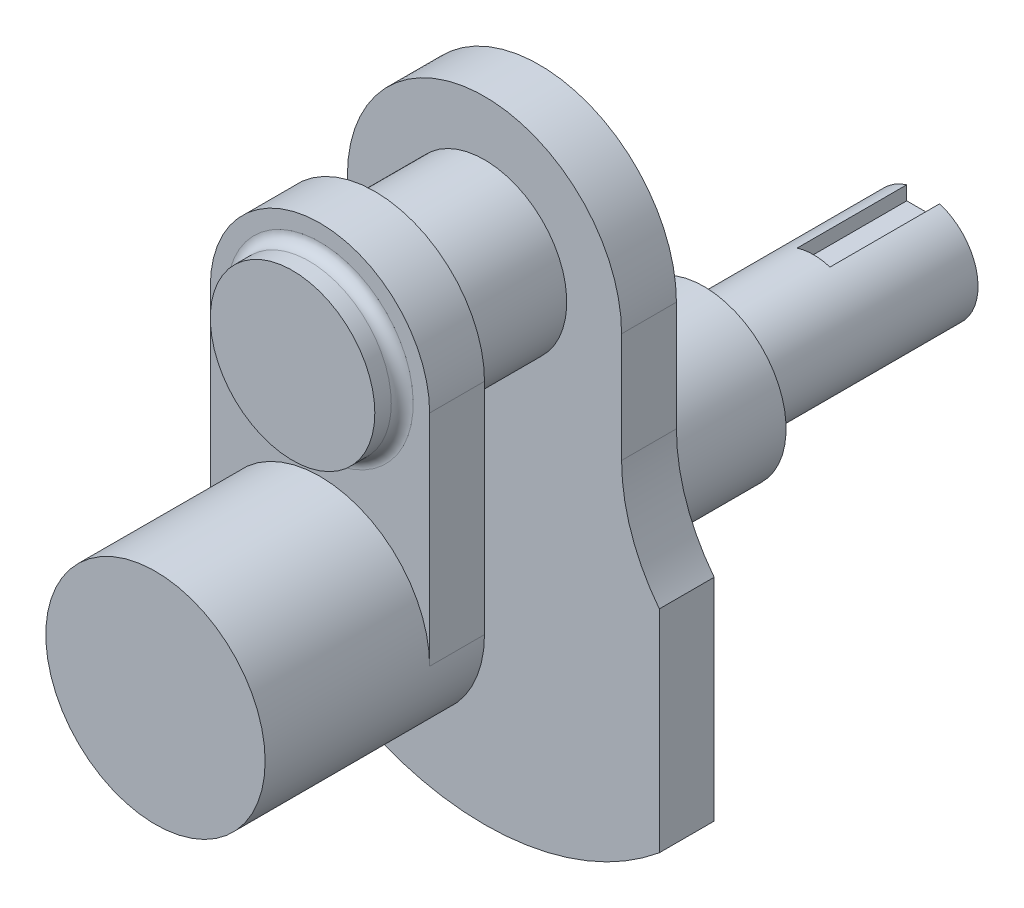
from build123d import *

# Parameters (mm, degrees)
IZIM1_W                          = 40
IZIM1_H                          = 40
Y_KSEKLIK_EKSTR_ZYON1_DEPTH      = 20
KES_EKSTR_ZYON1_DEPTH            = 40
IZIM4_W                          = 10
IZIM4_H                          = 65
Y_KSEKLIK_EKSTR_ZYON2_DEPTH      = 40
KES_EKSTR_ZYON2_DEPTH            = 40
Y_KSEKLIK_EKSTR_ZYON3_DEPTH      = 5
Y_KSEKLIK_EKSTR_ZYON3_DEPTH_BACK = 30
IZIM8_R                          = 15
RADYUS1_R                        = 2
IZIM10_R                         = 15
Y_KSEKLIK_EKSTR_ZYON4_DEPTH      = 10
IZIM10_3_R                       = 15
Y_KSEKLIK_EKSTR_ZYON5_DEPTH      = 10
IZIM18_R                         = 15
Y_KSEKLIK_EKSTR_ZYON6_DEPTH      = 30
IZIM19_R                         = 10
Y_KSEKLIK_EKSTR_ZYON7_DEPTH      = 40
RADYUS2_R                        = 2
RADYUS3_R                        = 2
IZIM21_R                         = 1
KES_EKSTR_ZYON3_DEPTH            = 20
KES_EKSTR_ZYON4_START            = -20
KES_EKSTR_ZYON4_DEPTH            = 20


with BuildPart() as part:
    # Çizim1 → Yükseklik-Ekstrüzyon1 (new, symmetric)
    with BuildSketch(Plane.XY):
        with Locations((-20, 20)):
            Rectangle(IZIM1_W, IZIM1_H)
    extrude(amount=Y_KSEKLIK_EKSTR_ZYON1_DEPTH, both=True)

    # Çizim3 → Kes-Ekstrüzyon1 (cut)
    with BuildSketch(Plane.XY.offset(20)):
        with BuildLine():
            Line((-40, 20), (-40, 0))
            Line((-40, 0), (-20, 0))
            ThreePointArc((-20, 0), (-34.142135624, 5.857864376), (-40, 20))
        make_face()
        with BuildLine():
            ThreePointArc((0, 20), (-5.857864376, 5.857864376), (-20, 0))
            Line((-20, 0), (0, 0))
            Line((0, 0), (0, 20))
        make_face()
        with BuildLine():
            Line((-40, 40), (-40, 20))
            ThreePointArc((-40, 20), (-34.142135624, 34.142135624), (-20, 40))
            Line((-20, 40), (-40, 40))
        make_face()
        with BuildLine():
            ThreePointArc((-20, 40), (-5.857864376, 34.142135624), (0, 20))
            Line((0, 20), (0, 40))
            Line((0, 40), (-20, 40))
        make_face()
    extrude(amount=-KES_EKSTR_ZYON1_DEPTH, mode=Mode.SUBTRACT)

    # Çizim4 → Yükseklik-Ekstrüzyon2 (add)
    with BuildSketch(Plane(origin=(0, 0, 0), x_dir=(0, 0, -1), z_dir=(1, 0, 0))):
        with Locations((15, 52.5)):
            Rectangle(IZIM4_W, IZIM4_H)
    extrude(amount=-Y_KSEKLIK_EKSTR_ZYON2_DEPTH)

    # Çizim7 → Kes-Ekstrüzyon2 (cut)
    with BuildSketch(Plane.XY.offset(-10)):
        with BuildLine():
            Line((0, 60), (0, 85))
            Line((0, 85), (-40, 85))
            Line((-40, 85), (-40, 60))
            ThreePointArc((-40, 60), (-20, 80), (0, 60))
        make_face()
    extrude(amount=-KES_EKSTR_ZYON2_DEPTH, mode=Mode.SUBTRACT)

    # Çizim8 → Yükseklik-Ekstrüzyon3 (add, two sides: drawn at the far end of the back side and taken through both)
    with BuildSketch(Plane.XY.offset(-10).offset(-Y_KSEKLIK_EKSTR_ZYON3_DEPTH_BACK)):
        with Locations((-20, 60)):
            Circle(IZIM8_R)
    extrude(amount=Y_KSEKLIK_EKSTR_ZYON3_DEPTH + Y_KSEKLIK_EKSTR_ZYON3_DEPTH_BACK)

    # Radyus1
    radyus1_edges = [part.edges().sort_by_distance(p)[0] for p in [
        (-35, 60, -10),
    ]]
    fillet(radyus1_edges, radius=RADYUS1_R)



with BuildPart() as body_2:
    # Çizim10 → Yükseklik-Ekstrüzyon4 (new body)
    with BuildSketch(Plane(origin=(0, 0, -40), x_dir=(-1, 0, 0), z_dir=(0, 0, -1))):
        with BuildLine():
            ThreePointArc((45, 60), (20, 85), (-5, 60))
            Line((-5, 60), (-5, 40))
            ThreePointArc((-5, 40), (-6.768788262, 29.424432633), (-11.882623085, 20))
            Line((-11.882623085, 20), (-11.882623085, -18.516208863))
            ThreePointArc((-11.882623085, -18.516208863), (20, -30), (51.882623085, -18.516208863))
            Line((51.882623085, -18.516208863), (51.882623085, 20))
            ThreePointArc((51.882623085, 20), (46.768788262, 29.424432633), (45, 40))
            Line((45, 40), (45, 60))
        make_face()
        with Locations((20, 60)):
            Circle(IZIM10_R, mode=Mode.SUBTRACT)
    extrude(amount=Y_KSEKLIK_EKSTR_ZYON4_DEPTH)


with BuildPart() as part_1:
    add(part.part)

    add(body_2.part)  # Yükseklik-Ekstrüzyon5 merges body 2
    # Çizim10<3> → Yükseklik-Ekstrüzyon5 (add)
    with BuildSketch(Plane(origin=(0, 0, -40), x_dir=(-1, 0, 0), z_dir=(0, 0, -1))):
        with Locations((20, 60)):
            Circle(IZIM10_3_R)
    extrude(amount=Y_KSEKLIK_EKSTR_ZYON5_DEPTH)

    # Çizim18 → Yükseklik-Ekstrüzyon6 (add)
    with BuildSketch(Plane(origin=(0, 0, -50), x_dir=(-1, 0, 0), z_dir=(0, 0, -1))):
        with Locations((20, 20)):
            Circle(IZIM18_R)
    extrude(amount=Y_KSEKLIK_EKSTR_ZYON6_DEPTH)

    # Çizim19 → Yükseklik-Ekstrüzyon7 (add)
    with BuildSketch(Plane(origin=(0, 0, -80), x_dir=(-1, 0, 0), z_dir=(0, 0, -1))):
        with Locations((20, 20)):
            Circle(IZIM19_R)
    extrude(amount=Y_KSEKLIK_EKSTR_ZYON7_DEPTH)

    # Radyus2
    radyus2_edges = [part_1.edges().sort_by_distance(p)[0] for p in [
        (-5, 20, -50),
    ]]
    fillet(radyus2_edges, radius=RADYUS2_R)

    # Radyus3
    radyus3_edges = [part_1.edges().sort_by_distance(p)[0] for p in [
        (-10, 20, -80),
    ]]
    fillet(radyus3_edges, radius=RADYUS3_R)

    # Çizim21 → Kes-Ekstrüzyon3 (cut)
    with BuildSketch(Plane(origin=(0, 0, -120), x_dir=(-1, 0, 0), z_dir=(0, 0, -1))):
        with Locations((20, 20)):
            Circle(IZIM21_R)
    extrude(amount=-KES_EKSTR_ZYON3_DEPTH, mode=Mode.SUBTRACT)

    # Çizim22 → Kes-Ekstrüzyon4 (cut)
    with BuildSketch(Plane(origin=(0, 0, -120), x_dir=(-1, 0, 0), z_dir=(0, 0, -1)).offset(KES_EKSTR_ZYON4_START)):
        with BuildLine():
            Line((17, 27), (20, 27))
            Line((20, 27), (23, 27))
            Line((23, 27), (23, 29.539392014))
            ThreePointArc((23, 29.539392014), (20, 30), (17, 29.539392014))
            Line((17, 29.539392014), (17, 27))
        make_face()
    extrude(amount=KES_EKSTR_ZYON4_DEPTH, mode=Mode.SUBTRACT)


solid = part_1.part
